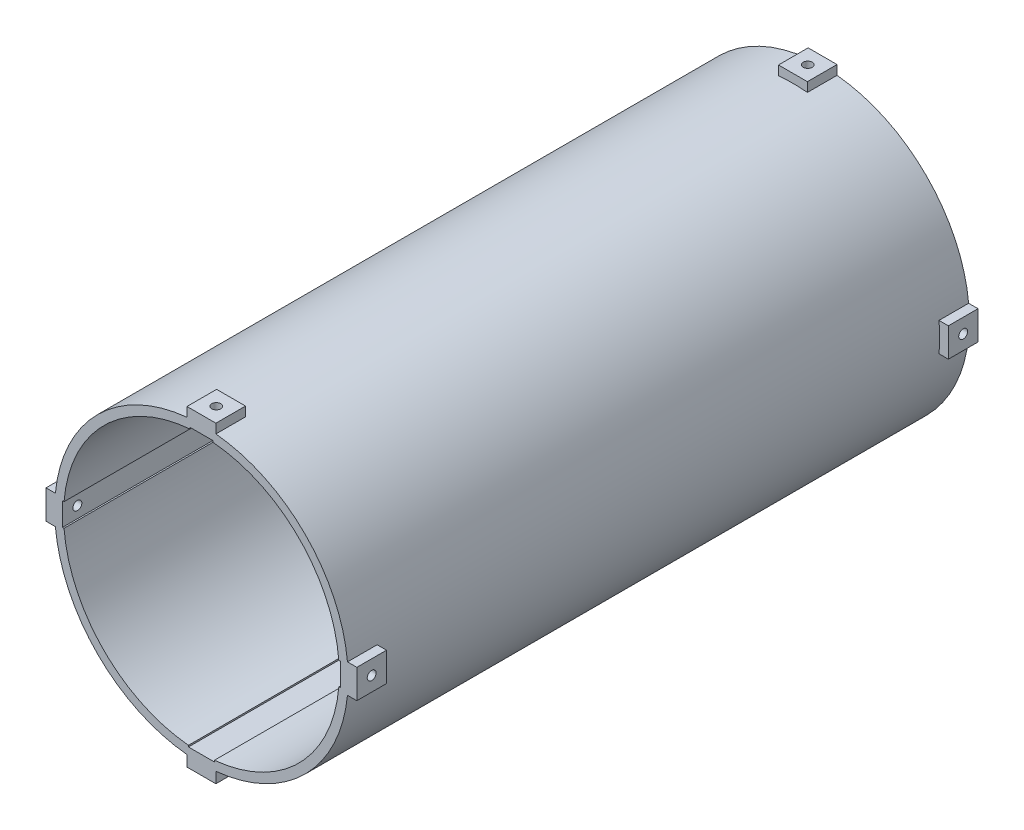
from build123d import *

# Parameters (mm, degrees)
EXTRUDE_1_DEPTH          = 419
CUT_EXTRUDE_START        = -20
SKETCH_2_R               = 119
SKETCH_2_R_2             = 99
CUT_EXTRUDE_1_DEPTH      = 379
SKETCH_3_R               = 93
CUT_EXTRUDE_2_DEPTH      = 420
SKETCH_4_W               = 17.5
SKETCH_4_H               = 1
SKETCH_4_W_2             = 1
SKETCH_4_H_2             = 15.5
SKETCH_4_W_3             = 15.5
CUT_EXTRUDE_3_DEPTH      = 420
SKETCH_5_R               = 3
CUT_EXTRUDE_4_DEPTH      = 12.158706001
PATTERN_CIRCULAR_1_COUNT = 4


with BuildPart() as part:
    # 草图1 → 凸台-拉伸1 (new body)
    with BuildSketch(Plane.XY):
        with BuildLine():
            Line((-9.75, -98.518716496), (-9.75, -105.83522676))
            Line((-9.75, -105.83522676), (9.75, -105.83522676))
            Line((9.75, -105.83522676), (9.75, -98.518716496))
            ThreePointArc((9.75, -98.518716496), (70.003571337, -70.003571337), (98.518716496, -9.75))
            Line((98.518716496, -9.75), (104.83522676, -9.75))
            Line((104.83522676, -9.75), (104.83522676, 9.75))
            Line((104.83522676, 9.75), (98.518716496, 9.75))
            ThreePointArc((98.518716496, 9.75), (70.003571337, 70.003571337), (9.75, 98.518716496))
            Line((9.75, 98.518716496), (9.75, 104.83522676))
            Line((9.75, 104.83522676), (-9.75, 104.83522676))
            Line((-9.75, 104.83522676), (-9.75, 98.518716496))
            ThreePointArc((-9.75, 98.518716496), (-70.003571337, 70.003571337), (-98.518716496, 9.75))
            Line((-98.518716496, 9.75), (-104.83522676, 9.75))
            Line((-104.83522676, 9.75), (-104.83522676, -9.75))
            Line((-104.83522676, -9.75), (-98.518716496, -9.75))
            ThreePointArc((-98.518716496, -9.75), (-70.003571337, -70.003571337), (-9.75, -98.518716496))
        make_face()
    extrude(amount=EXTRUDE_1_DEPTH)

    # 草图2 → 切除-拉伸1 (cut)
    with BuildSketch(Plane.XY.offset(419).offset(CUT_EXTRUDE_START)):
        Circle(SKETCH_2_R)
        Circle(SKETCH_2_R_2, mode=Mode.SUBTRACT)
    extrude(amount=-CUT_EXTRUDE_1_DEPTH, mode=Mode.SUBTRACT)

    # 草图3 → 切除-拉伸2 (cut, through all)
    with BuildSketch(Plane.XY.offset(419)):
        Circle(SKETCH_3_R)
    extrude(amount=-CUT_EXTRUDE_2_DEPTH, mode=Mode.SUBTRACT)

    # 草图4 → 切除-拉伸3 (cut, through all)
    with BuildSketch(Plane.XY.offset(419)):
        with Locations((0, -93.087458654)):
            Rectangle(SKETCH_4_W, SKETCH_4_H)
        with Locations((-93.176520759, 0)):
            Rectangle(SKETCH_4_W_2, SKETCH_4_H_2)
        with Locations((0, 93.176520759)):
            Rectangle(SKETCH_4_W_3, SKETCH_4_H)
        with Locations((93.176520759, 0)):
            Rectangle(SKETCH_4_W_2, SKETCH_4_H_2)
    extrude(amount=-CUT_EXTRUDE_3_DEPTH, mode=Mode.SUBTRACT)

    # 草图5 → 切除-拉伸4 (cut, through all)
    with BuildSketch(Plane(origin=(-93.676520759, 0, 0), x_dir=(0, 0, -1), z_dir=(1, 0, 0))):
        with Locations((-409, 0)):
            Circle(SKETCH_5_R)
        with Locations((-10, 0)):
            Circle(SKETCH_5_R)
    cut_extrude_4 = extrude(amount=-CUT_EXTRUDE_4_DEPTH, mode=Mode.SUBTRACT)

    # 阵列(圆周)1: 切除-拉伸4 ×4 about axis
    pattern_circular_1_axis = Axis((0, 0, 1000), (0, 0, -1))
    for i in range(1, PATTERN_CIRCULAR_1_COUNT):
        add(cut_extrude_4.rotate(pattern_circular_1_axis, i * 360 / PATTERN_CIRCULAR_1_COUNT), mode=Mode.SUBTRACT)


solid = part.part
